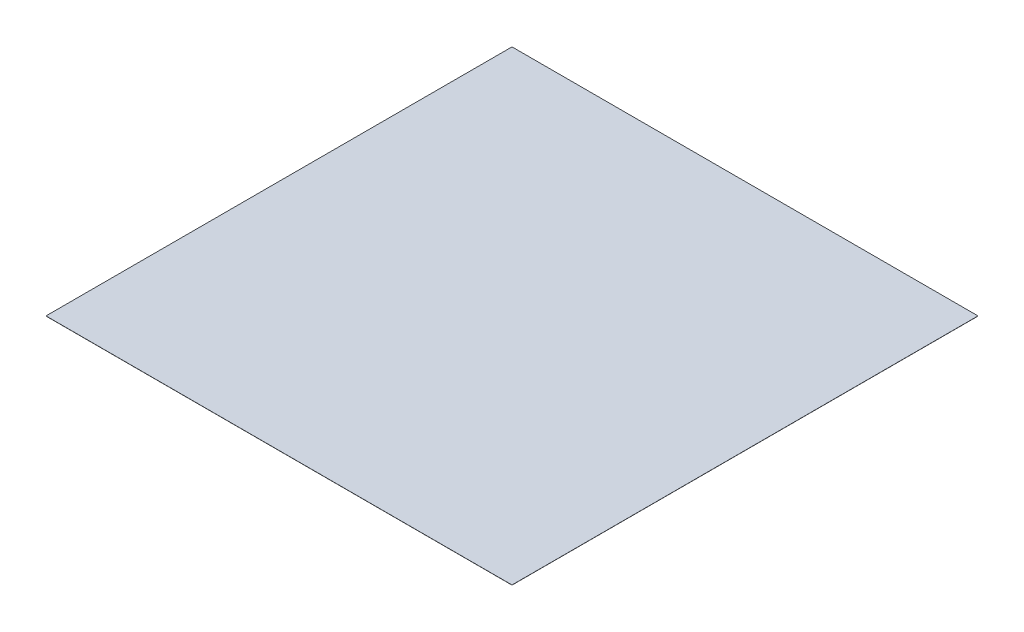
from build123d import *

# Parameters (mm, degrees)
SKETCH1_W           = 3000
SKETCH1_H           = 3000
BOSS_EXTRUDE1_DEPTH = 1


with BuildPart() as part:
    # Sketch1 → Boss-Extrude1 (new body)
    with BuildSketch(Plane(origin=(0, 0, 0), x_dir=(1, 0, 0), z_dir=(0, 1, 0))):
        with Locations((76.660900951, -519.465903768)):
            Rectangle(SKETCH1_W, SKETCH1_H)
    extrude(amount=BOSS_EXTRUDE1_DEPTH)


solid = part.part
